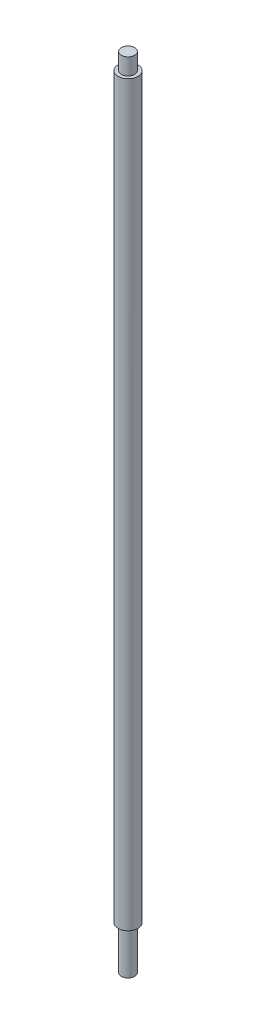
from build123d import *

# Parameters (mm, degrees)
SKETCH1_R           = 6
BOSS_EXTRUDE1_DEPTH = 240
SKETCH2_R           = 6
SKETCH2_R_2         = 4
CUT_EXTRUDE1_DEPTH  = 10
SKETCH3_R           = 6
SKETCH3_R_2         = 4
CUT_EXTRUDE2_DEPTH  = 25.999999878


with BuildPart() as part:
    # Sketch1 → Boss-Extrude1 (new body, symmetric)
    with BuildSketch(Plane(origin=(0, 0, 0), x_dir=(1, 0, 0), z_dir=(0, 1, 0))):
        Circle(SKETCH1_R)
    extrude(amount=BOSS_EXTRUDE1_DEPTH, both=True)

    # Sketch2 → Cut-Extrude1 (cut)
    with BuildSketch(Plane(origin=(0, 240, 0), x_dir=(1, 0, 0), z_dir=(0, 1, 0))):
        Circle(SKETCH2_R)
        Circle(SKETCH2_R_2, mode=Mode.SUBTRACT)
    extrude(amount=-CUT_EXTRUDE1_DEPTH, mode=Mode.SUBTRACT)

    # Sketch3 → Cut-Extrude2 (cut)
    with BuildSketch(Plane.XZ.offset(240)):
        Circle(SKETCH3_R)
        Circle(SKETCH3_R_2, mode=Mode.SUBTRACT)
    extrude(amount=-CUT_EXTRUDE2_DEPTH, mode=Mode.SUBTRACT)


solid = part.part
